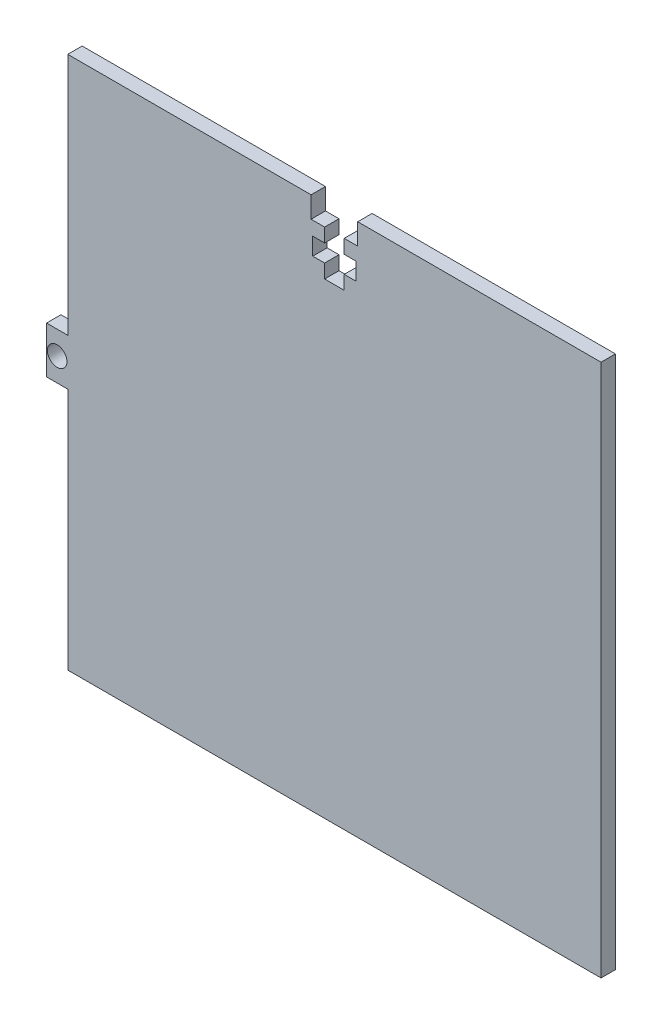
from build123d import *

# Parameters (mm, degrees)
SKETCH1_W           = 80
SKETCH1_H           = 80
BOSS_EXTRUDE1_DEPTH = 2.158807247
SKETCH2_W           = 7
SKETCH2_H           = 3.175
CUT_EXTRUDE1_DEPTH  = 3.158807247
CUT_EXTRUDE2_DEPTH  = 3.158807247
SKETCH4_W           = 3.18
SKETCH4_H           = 7
SKETCH4_R           = 1.47
BOSS_EXTRUDE2_DEPTH = 2.158807


with BuildPart() as part:
    # Sketch1 → Boss-Extrude1 (new body)
    with BuildSketch(Plane.XY):
        Rectangle(SKETCH1_W, SKETCH1_H)
    extrude(amount=BOSS_EXTRUDE1_DEPTH)

    # Sketch2 → Cut-Extrude1 (cut, through all)
    with BuildSketch(Plane.XY.offset(2.158807247)):
        with Locations((0, 38.4125)):
            Rectangle(SKETCH2_W, SKETCH2_H)
    extrude(amount=-CUT_EXTRUDE1_DEPTH, mode=Mode.SUBTRACT)

    # Sketch3 → Cut-Extrude2 (cut, through all)
    with BuildSketch(Plane.XY.offset(2.158807247)):
        Polygon((1.47, 34.75), (3.25, 34.75), (3.25, 32.15), (1.47, 32.15), (1.47, 30.075), (-1.47, 30.075), (-1.47, 32.15), (-3.25, 32.15), (-3.25, 34.75), (-1.47, 34.75), (-1.47, 36.825), (1.47, 36.825), align=None)
    extrude(amount=-CUT_EXTRUDE2_DEPTH, mode=Mode.SUBTRACT)

    # Sketch4 → Boss-Extrude2 (add)
    with BuildSketch(Plane.XY.offset(2.158807247)):
        with Locations((-41.59, 0)):
            Rectangle(SKETCH4_W, SKETCH4_H)
        with Locations((-41.59, 0)):
            Circle(SKETCH4_R, mode=Mode.SUBTRACT)
    extrude(amount=-BOSS_EXTRUDE2_DEPTH)


solid = part.part
